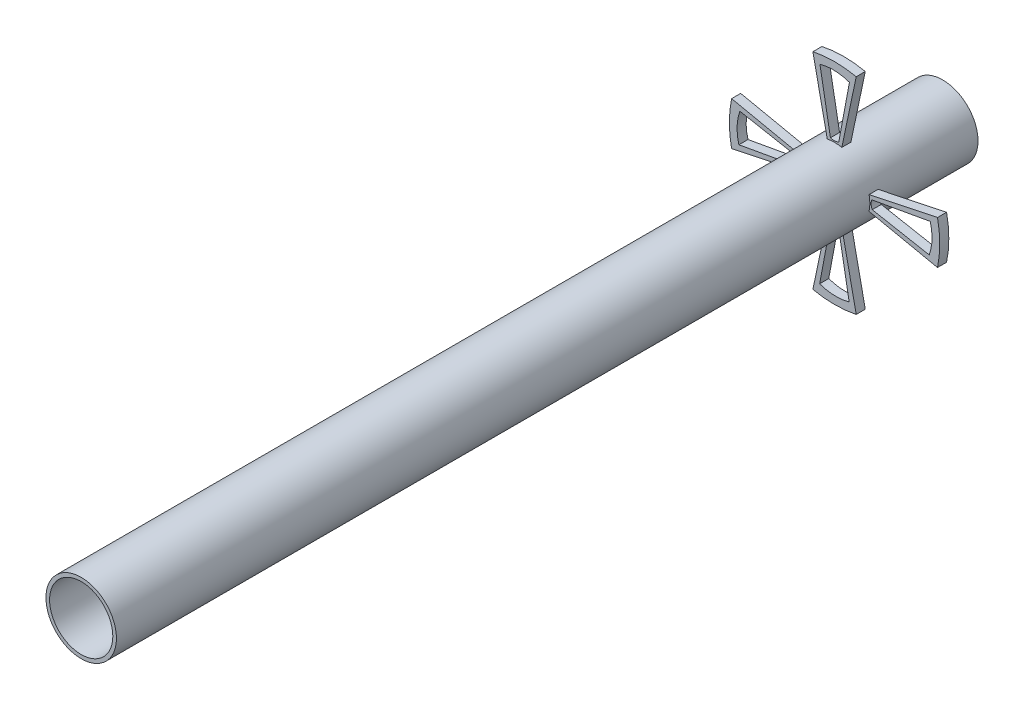
from build123d import *

# Parameters (mm, degrees)
BOSS_EXTRUDE5_DEPTH      = 25
BOSS_EXTRUDE5_2_DEPTH    = 25
BOSS_EXTRUDE5_3_DEPTH    = 25
BOSS_EXTRUDE5_4_DEPTH    = 25
SKETCH5_R                = 97.102354857
SKETCH5_R_2              = 87.102354857
BOSS_EXTRUDE6_DEPTH      = 2100
BOSS_EXTRUDE6_DEPTH_BACK = 273


with BuildPart() as part:
    # Sketch4 → Boss-Extrude5 (new body)
    with BuildSketch(Plane.XY):
        with BuildLine():
            Line((-283.528917558, -59.677513544), (-95.020352129, -20))
            ThreePointArc((-95.020352129, -20), (-97.102354857, 0), (-95.020352129, 20))
            Line((-95.020352129, 20), (-283.528917558, 59.677513544))
            ThreePointArc((-283.528917558, 59.677513544), (-289.741354857, 0), (-283.528917558, -59.677513544))
        make_face()
        with BuildLine():
            ThreePointArc((-103.749908429, 11.618296452), (-100.811412037, 0.266569794), (-102.448791191, -11.344435703))
            Line((-102.448791191, -11.344435703), (-263.440278466, -40.343403868))
            ThreePointArc((-263.440278466, -40.343403868), (-268.408850648, 0.533483895), (-260.728236447, 40.988580338))
            Line((-260.728236447, 40.988580338), (-103.749908429, 11.618296452))
        make_face(mode=Mode.SUBTRACT)
    extrude(amount=BOSS_EXTRUDE5_DEPTH)



with BuildPart() as body_2:
    # Sketch4 → Boss-Extrude5 2 (new body)
    with BuildSketch(Plane.XY):
        with BuildLine():
            Line((-59.677513544, 283.528917558), (-20, 95.020352129))
            ThreePointArc((-20, 95.020352129), (0, 97.102354857), (20, 95.020352129))
            Line((20, 95.020352129), (59.677513544, 283.528917558))
            ThreePointArc((59.677513544, 283.528917558), (0, 289.741354857), (-59.677513544, 283.528917558))
        make_face()
        with BuildLine():
            Line((40.988580338, 260.728236447), (11.618296452, 103.749908429))
            ThreePointArc((11.618296452, 103.749908429), (0.266569794, 100.811412037), (-11.344435703, 102.448791191))
            Line((-11.344435703, 102.448791191), (-40.343403868, 263.440278466))
            ThreePointArc((-40.343403868, 263.440278466), (0.533483895, 268.408850648), (40.988580338, 260.728236447))
        make_face(mode=Mode.SUBTRACT)
    extrude(amount=BOSS_EXTRUDE5_2_DEPTH)


with BuildPart() as body_3:
    # Sketch4 → Boss-Extrude5 3 (new body)
    with BuildSketch(Plane.XY):
        with BuildLine():
            ThreePointArc((97.102354857, 0), (96.580451619, -10.054038186), (95.020352129, -20))
            Line((95.020352129, -20), (283.528917558, -59.677513544))
            ThreePointArc((283.528917558, -59.677513544), (289.741354857, 0), (283.528917558, 59.677513544))
            Line((283.528917558, 59.677513544), (95.020352129, 20))
            ThreePointArc((95.020352129, 20), (96.580451619, 10.054038186), (97.102354857, 0))
        make_face()
        with BuildLine():
            Line((260.728236447, -40.988580338), (103.749908429, -11.618296452))
            ThreePointArc((103.749908429, -11.618296452), (100.811412037, -0.266569794), (102.448791191, 11.344435703))
            Line((102.448791191, 11.344435703), (263.440278466, 40.343403868))
            ThreePointArc((263.440278466, 40.343403868), (268.408850648, -0.533483895), (260.728236447, -40.988580338))
        make_face(mode=Mode.SUBTRACT)
    extrude(amount=BOSS_EXTRUDE5_3_DEPTH)


with BuildPart() as body_4:
    # Sketch4 → Boss-Extrude5 4 (new body)
    with BuildSketch(Plane.XY):
        with BuildLine():
            ThreePointArc((20, -95.020352129), (0, -97.102354857), (-20, -95.020352129))
            Line((-20, -95.020352129), (-59.677513544, -283.528917558))
            ThreePointArc((-59.677513544, -283.528917558), (0, -289.741354857), (59.677513544, -283.528917558))
            Line((59.677513544, -283.528917558), (20, -95.020352129))
        make_face()
        with BuildLine():
            Line((-40.988580338, -260.728236447), (-11.618296452, -103.749908429))
            ThreePointArc((-11.618296452, -103.749908429), (-0.266569794, -100.811412037), (11.344435703, -102.448791191))
            Line((11.344435703, -102.448791191), (40.343403868, -263.440278466))
            ThreePointArc((40.343403868, -263.440278466), (-0.533483895, -268.408850648), (-40.988580338, -260.728236447))
        make_face(mode=Mode.SUBTRACT)
    extrude(amount=BOSS_EXTRUDE5_4_DEPTH)


with BuildPart() as part_1:
    add(part.part)

    add(body_2.part)  # Boss-Extrude6 merges body 2

    add(body_3.part)  # Boss-Extrude6 merges body 3

    add(body_4.part)  # Boss-Extrude6 merges body 4
    # Sketch5 → Boss-Extrude6 (add, two sides)
    with BuildSketch(Plane.XY) as boss_extrude6_sk:
        Circle(SKETCH5_R)
        Circle(SKETCH5_R_2, mode=Mode.SUBTRACT)
    extrude(amount=BOSS_EXTRUDE6_DEPTH)
    extrude(boss_extrude6_sk.sketch, amount=-BOSS_EXTRUDE6_DEPTH_BACK)


solid = part_1.part
